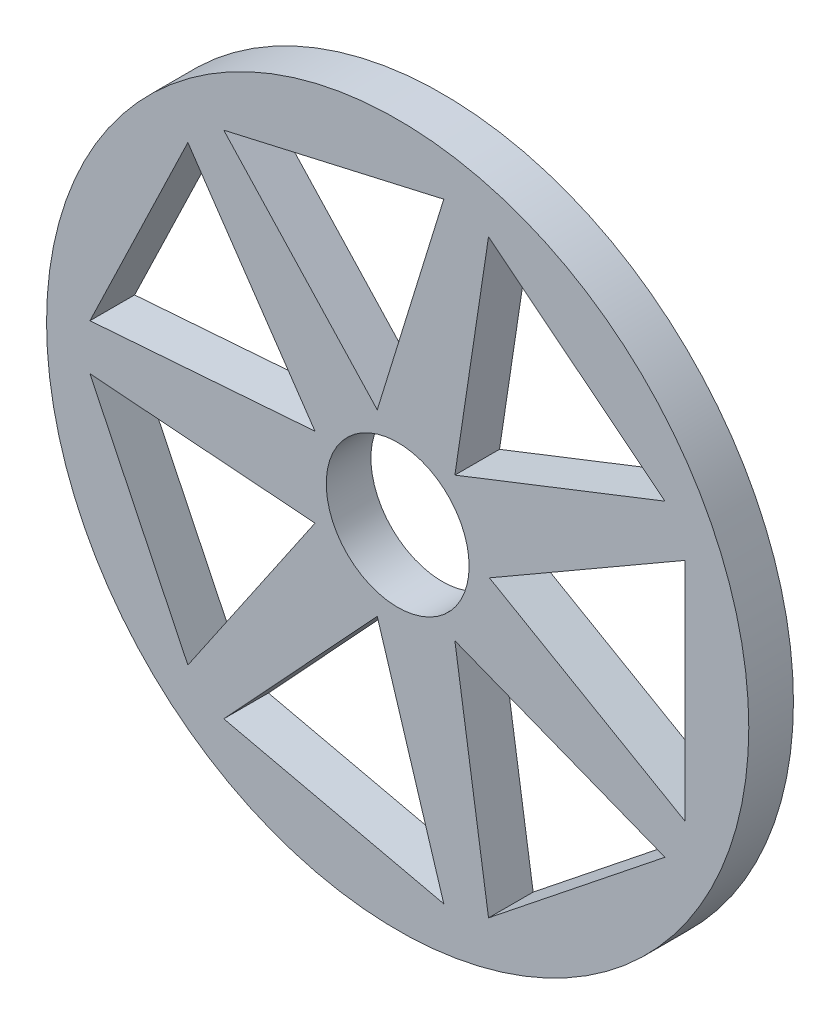
from build123d import *

# Parameters (mm, degrees)
SKETCH1_R           = 54.929
SKETCH1_R_2         = 11.176
BOSS_EXTRUDE1_DEPTH = 6.985
CUT_EXTRUDE1_DEPTH  = 6.985


with BuildPart() as part:
    # Sketch1 → Boss-Extrude1 (new body)
    with BuildSketch(Plane.XY):
        with Locations((-9.1425, 0)):
            Circle(SKETCH1_R)
        with Locations((-9.1425, 0)):
            Circle(SKETCH1_R_2, mode=Mode.SUBTRACT)
    extrude(amount=BOSS_EXTRUDE1_DEPTH)

    # Sketch2 → Cut-Extrude1 (cut)
    with BuildSketch(Plane.XY.offset(6.985)):
        Polygon((35.7865, -17.654216531), (5.2085, 0), (35.7865, 17.654216531), align=None)
        Polygon((5.067651025, -46.134130643), (-0.194797854, -11.220063605), (32.67289559, -24.119682709), align=None)
        Polygon((-36.351731506, -39.874103416), (-12.335897923, -13.991190468), (-1.928554578, -47.730968917), align=None)
        Polygon((-57.282007746, -3.588063033), (-22.072304223, -6.22666554), (-41.962252786, -35.399861997), align=None)
        Polygon((-41.962252786, 35.399861997), (-22.072304223, 6.22666554), (-57.282007746, 3.588063033), align=None)
        Polygon((-1.928554578, 47.730968917), (-12.335897923, 13.991190468), (-36.351731506, 39.874103416), align=None)
        Polygon((32.67289559, 24.119682709), (-0.194797854, 11.220063605), (5.067651025, 46.134130643), align=None)
    extrude(amount=-CUT_EXTRUDE1_DEPTH, mode=Mode.SUBTRACT)


solid = part.part
